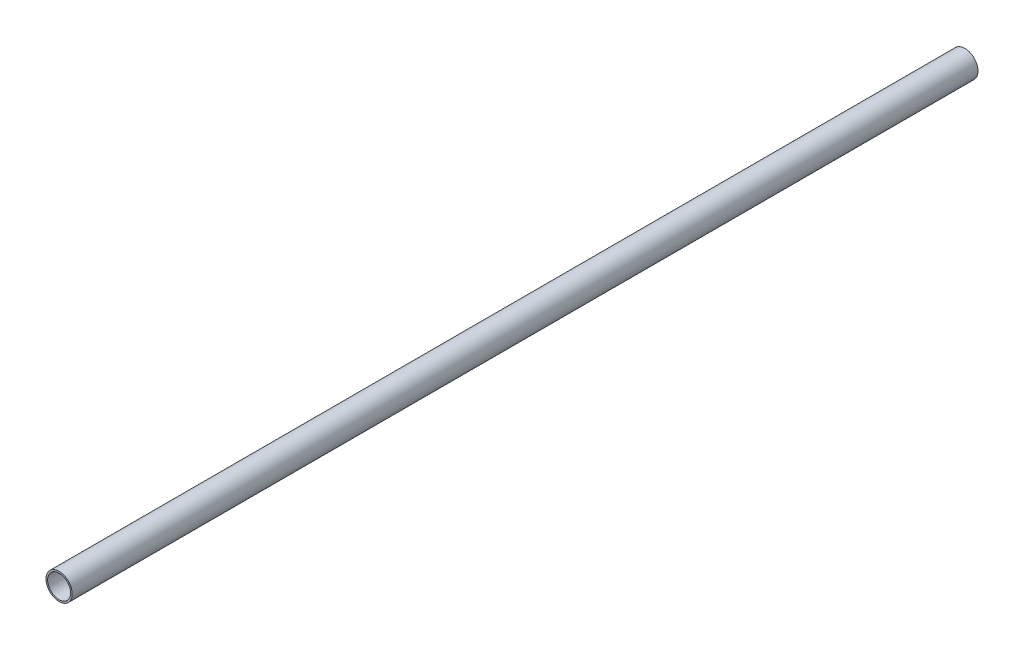
from build123d import *

# Parameters (mm, degrees)
SKETCH_1_R      = 8
SKETCH_1_R_2    = 7
EXTRUDE_1_DEPTH = 552


with BuildPart() as part:
    # Эскиз1 → Бобышка-Вытянуть1 (new body)
    with BuildSketch(Plane.XY):
        Circle(SKETCH_1_R)
        Circle(SKETCH_1_R_2, mode=Mode.SUBTRACT)
    extrude(amount=EXTRUDE_1_DEPTH)


solid = part.part
